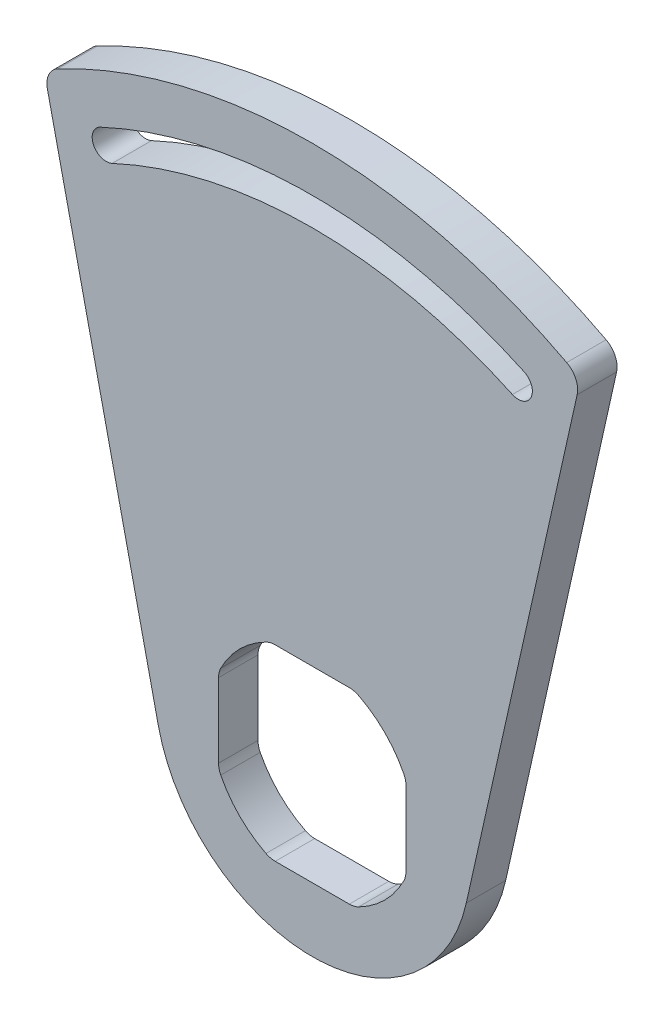
from build123d import *

# Parameters (mm, degrees)
BOSS_EXTRUDE1_DEPTH = 6.35
FILLET1_R           = 3.302
FILLET2_R           = 3.302


with BuildPart() as part:
    # Sketch1 → Boss-Extrude1 (new body)
    with BuildSketch(Plane.XY):
        with BuildLine():
            Line((-43.182028134, 76.689298909), (-24.787442952, -5.544607461))
            ThreePointArc((-24.787442952, -5.544607461), (0, -25.4), (24.787442952, -5.544607461))
            Line((24.787442952, -5.544607461), (43.182028134, 76.689298909))
            ThreePointArc((43.182028134, 76.689298909), (0, 88.011), (-43.182028134, 76.689298909))
        make_face()
        with BuildLine():
            Line((-6.704060429, 15.0876), (6.704060429, 15.0876))
            ThreePointArc((6.704060429, 15.0876), (11.674332957, 11.674332957), (15.0876, 6.704060429))
            Line((15.0876, 6.704060429), (15.0876, -6.704060429))
            ThreePointArc((15.0876, -6.704060429), (11.674332957, -11.674332957), (6.704060429, -15.0876))
            Line((6.704060429, -15.0876), (-6.704060429, -15.0876))
            ThreePointArc((-6.704060429, -15.0876), (-11.674332957, -11.674332957), (-15.0876, -6.704060429))
            Line((-15.0876, -6.704060429), (-15.0876, 6.704060429))
            ThreePointArc((-15.0876, 6.704060429), (-11.674332957, 11.674332957), (-6.704060429, 15.0876))
        make_face(mode=Mode.SUBTRACT)
        with BuildLine():
            ThreePointArc((-34.124988821, 73.18127185), (0, 80.7466), (34.124988821, 73.18127185))
            ThreePointArc((34.124988821, 73.18127185), (35.218416261, 70.177102101), (32.214247077, 69.083673111))
            ThreePointArc((32.214247077, 69.083673111), (0, 76.2254), (-32.214247077, 69.083673111))
            ThreePointArc((-32.214247077, 69.083673111), (-35.218416261, 70.177102101), (-34.124988821, 73.18127185))
        make_face(mode=Mode.SUBTRACT)
    extrude(amount=BOSS_EXTRUDE1_DEPTH)

    # Fillet1
    fillet1_edges = [part.edges().sort_by_distance(p)[0] for p in [
        (-15.0876, 6.704060429, 3.175),
        (-15.0876, -6.704060429, 3.175),
        (-6.704060429, -15.0876, 3.175),
        (6.704060429, -15.0876, 3.175),
        (15.0876, -6.704060429, 3.175),
        (15.0876, 6.704060429, 3.175),
        (6.704060429, 15.0876, 3.175),
        (-6.704060429, 15.0876, 3.175),
    ]]
    fillet(fillet1_edges, radius=FILLET1_R)

    # Fillet2
    fillet2_edges = [part.edges().sort_by_distance(p)[0] for p in [
        (43.182028134, 76.689298909, 3.175),
        (-43.182028134, 76.689298909, 3.175),
    ]]
    fillet(fillet2_edges, radius=FILLET2_R)


solid = part.part
